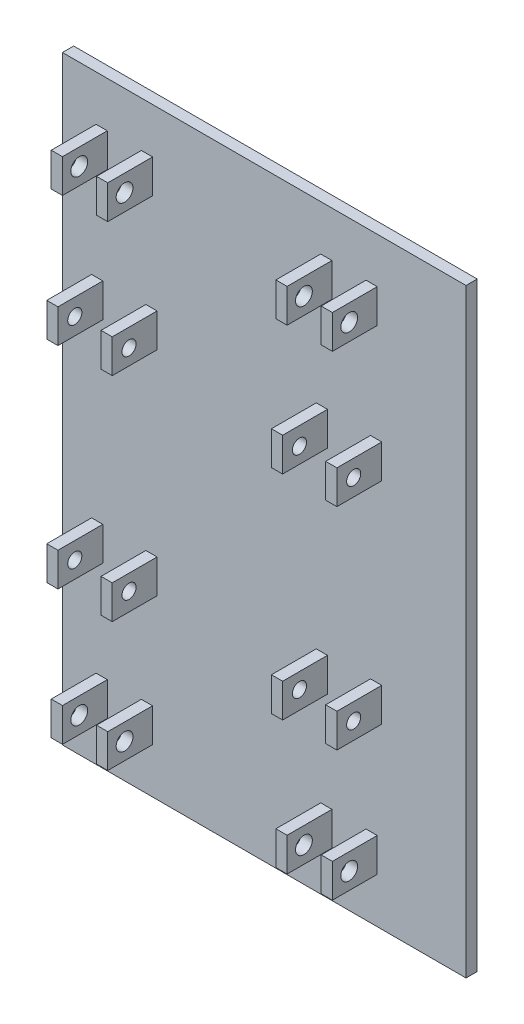
from build123d import *

# Parameters (mm, degrees)
SKETCH1_W               = 228.6
SKETCH1_H               = 339.725
BOSS_EXTRUDE1_DEPTH     = 6.35
SKETCH2_W               = 6.35
SKETCH2_H               = 19.05
BOSS_EXTRUDE2_DEPTH     = 25.4
CUT_EXTRUDE1_DEPTH      = 401.415210282
CUT_EXTRUDE1_DEPTH_BACK = 401.415210282
SKETCH3_R               = 4.7625
SKETCH3_R_2             = 4


with BuildPart() as part:
    # Sketch1 → Boss-Extrude1 (new body)
    with BuildSketch(Plane.XY):
        with Locations((114.3, -169.8625)):
            Rectangle(SKETCH1_W, SKETCH1_H)
    extrude(amount=BOSS_EXTRUDE1_DEPTH)

    # Sketch2 → Boss-Extrude2 (add)
    with BuildSketch(Plane.XY.offset(6.35)):
        with Locations((22.225, -35.2425)):
            Rectangle(SKETCH2_W, SKETCH2_H)
        with Locations((47.879, -35.2425)):
            Rectangle(SKETCH2_W, SKETCH2_H)
        with Locations((149.479, -35.2425)):
            Rectangle(SKETCH2_W, SKETCH2_H)
        with Locations((175.133, -35.2425)):
            Rectangle(SKETCH2_W, SKETCH2_H)
        with Locations((22.225, -304.4825)):
            Rectangle(SKETCH2_W, SKETCH2_H)
        with Locations((47.879, -304.4825)):
            Rectangle(SKETCH2_W, SKETCH2_H)
        with Locations((149.479, -304.4825)):
            Rectangle(SKETCH2_W, SKETCH2_H)
        with Locations((175.133, -304.4825)):
            Rectangle(SKETCH2_W, SKETCH2_H)
        with Locations((19.685, -110.1598)):
            Rectangle(SKETCH2_W, SKETCH2_H)
        with Locations((50.419, -109.5248)):
            Rectangle(SKETCH2_W, SKETCH2_H)
        with Locations((146.939, -109.5248)):
            Rectangle(SKETCH2_W, SKETCH2_H)
        with Locations((177.673, -110.1598)):
            Rectangle(SKETCH2_W, SKETCH2_H)
        with Locations((177.673, -229.5652)):
            Rectangle(SKETCH2_W, SKETCH2_H)
        with Locations((146.939, -230.2002)):
            Rectangle(SKETCH2_W, SKETCH2_H)
        with Locations((50.419, -230.2002)):
            Rectangle(SKETCH2_W, SKETCH2_H)
        with Locations((19.685, -229.5652)):
            Rectangle(SKETCH2_W, SKETCH2_H)
    extrude(amount=BOSS_EXTRUDE2_DEPTH)

    # Sketch3 → Cut-Extrude1 (cut, two sides: drawn at the far end of the back side and taken through both)
    with BuildSketch(Plane.ZY.offset(-19.05).offset(-CUT_EXTRUDE1_DEPTH_BACK)):
        with Locations((22.225, -35.2425)):
            Circle(SKETCH3_R)
        with Locations((22.225, -229.5652)):
            Circle(SKETCH3_R_2)
        with Locations((22.225, -304.4825)):
            Circle(SKETCH3_R)
        with Locations((22.225, -110.1598)):
            Circle(SKETCH3_R_2)
    extrude(amount=CUT_EXTRUDE1_DEPTH + CUT_EXTRUDE1_DEPTH_BACK, mode=Mode.SUBTRACT)


solid = part.part
